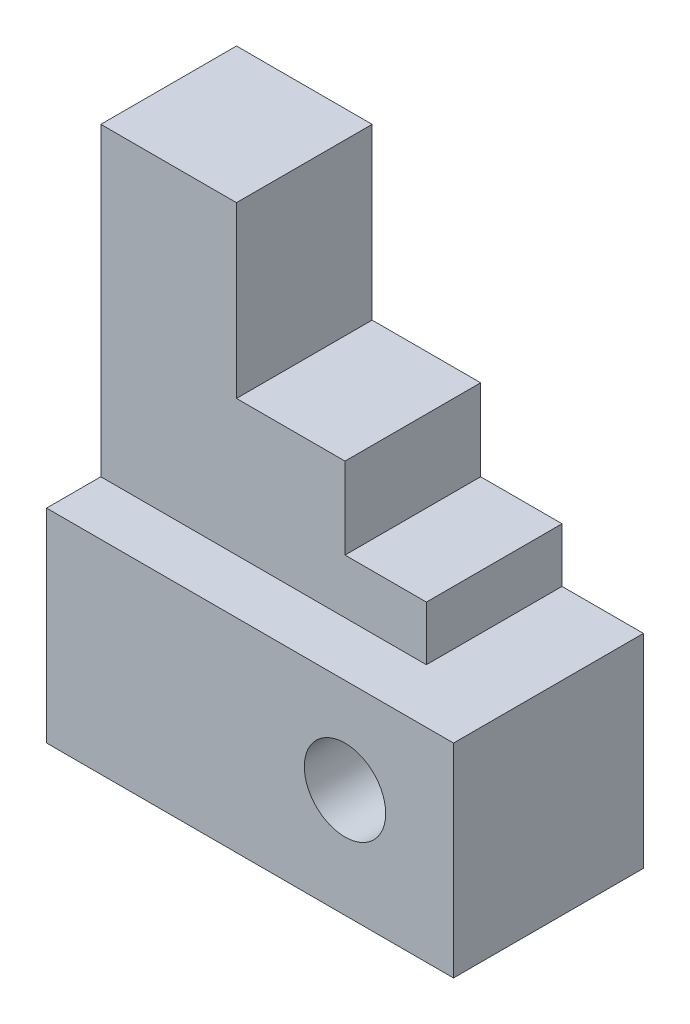
from build123d import *

# Parameters (mm, degrees)
SKETCH2_W           = 60
SKETCH2_H           = 28
BOSS_EXTRUDE1_DEPTH = 30
SKETCH3_R           = 6
CUT_EXTRUDE1_DEPTH  = 47
SKETCH4_W           = 48
SKETCH4_H           = 20
BOSS_EXTRUDE2_DEPTH = 8
SKETCH5_W           = 36
SKETCH5_H           = 20
BOSS_EXTRUDE3_DEPTH = 12
SKETCH6_W           = 20
SKETCH6_H           = 20
BOSS_EXTRUDE4_DEPTH = 25


with BuildPart() as part:
    # Sketch2 → Boss-Extrude1 (new body)
    with BuildSketch(Plane(origin=(0, 0, 0), x_dir=(1, 0, 0), z_dir=(0, 1, 0))):
        Rectangle(SKETCH2_W, SKETCH2_H)
    extrude(amount=BOSS_EXTRUDE1_DEPTH)

    # Sketch3 → Cut-Extrude1 (cut)
    with BuildSketch(Plane.XY.offset(14)):
        with Locations((14, 16)):
            Circle(SKETCH3_R)
    extrude(amount=-CUT_EXTRUDE1_DEPTH, mode=Mode.SUBTRACT)

    # Sketch4 → Boss-Extrude2 (add)
    with BuildSketch(Plane(origin=(0, 30, 0), x_dir=(1, 0, 0), z_dir=(0, 1, 0))):
        with Locations((-6, 4)):
            Rectangle(SKETCH4_W, SKETCH4_H)
    extrude(amount=BOSS_EXTRUDE2_DEPTH)

    # Sketch5 → Boss-Extrude3 (add)
    with BuildSketch(Plane(origin=(0, 38, 0), x_dir=(1, 0, 0), z_dir=(0, 1, 0))):
        with Locations((-12, 4)):
            Rectangle(SKETCH5_W, SKETCH5_H)
    extrude(amount=BOSS_EXTRUDE3_DEPTH)

    # Sketch6 → Boss-Extrude4 (add)
    with BuildSketch(Plane(origin=(0, 50, 0), x_dir=(1, 0, 0), z_dir=(0, 1, 0))):
        with Locations((-20, 4)):
            Rectangle(SKETCH6_W, SKETCH6_H)
    extrude(amount=BOSS_EXTRUDE4_DEPTH)


solid = part.part
